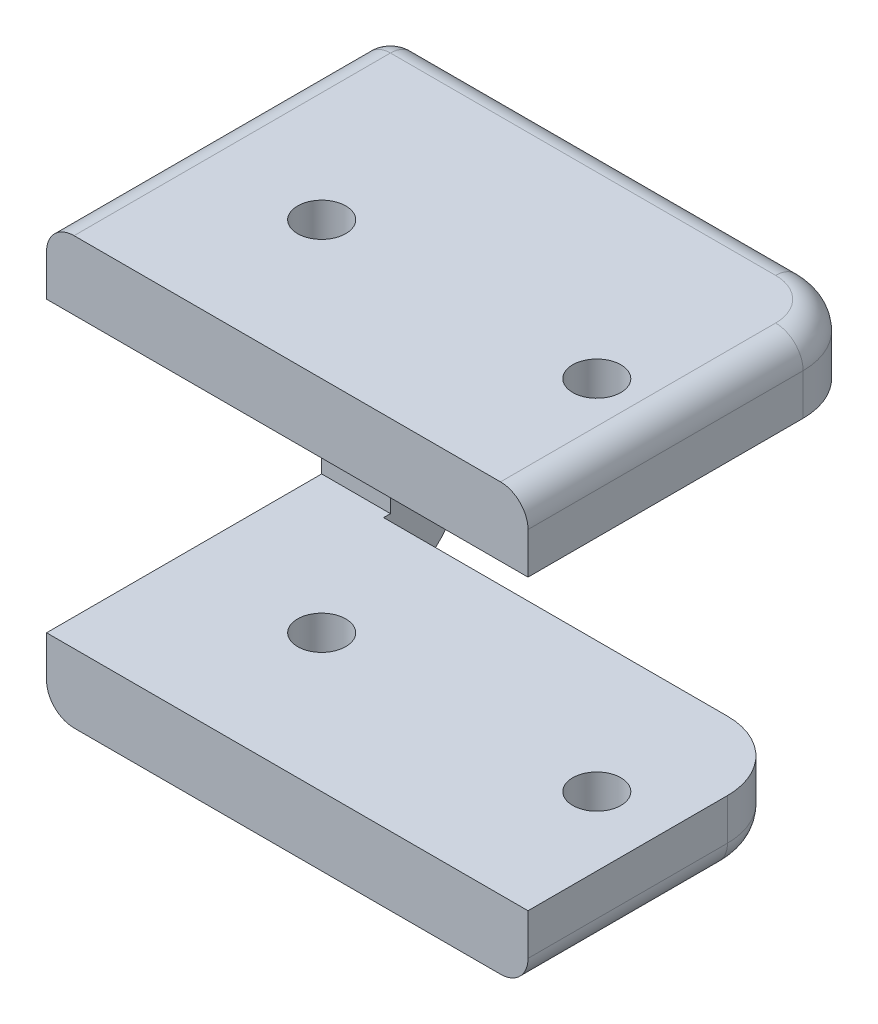
from build123d import *

# Parameters (mm, degrees)
SKETCH1_W           = 30
SKETCH1_H           = 25
SKETCH1_R           = 1.75
BOSS_EXTRUDE1_DEPTH = 5
BOSS_EXTRUDE2_DEPTH = 5
SKETCH3_W           = 19.5
SKETCH3_H           = 5
BOSS_EXTRUDE3_DEPTH = 30
SKETCH4_R           = 1.75
CUT_EXTRUDE1_DEPTH  = 32
FILLET1_R           = 5
FILLET2_R           = 2


with BuildPart() as part:
    # Sketch1 → Boss-Extrude1 (new body)
    with BuildSketch(Plane(origin=(0, 0, 0), x_dir=(1, 0, 0), z_dir=(0, 1, 0))):
        Rectangle(SKETCH1_W, SKETCH1_H)
        with Locations((-10, -2.5)):
            Circle(SKETCH1_R, mode=Mode.SUBTRACT)
        with Locations((10, -2.5)):
            Circle(SKETCH1_R, mode=Mode.SUBTRACT)
    extrude(amount=BOSS_EXTRUDE1_DEPTH)

    # Sketch2 → Boss-Extrude2 (add)
    with BuildSketch(Plane.ZY.offset(15)):
        Polygon((-12.5, 5), (12.5, 5), (12.5, 0), (-7.5, 0), (-7.5, -21), (12.5, -21), (12.5, -26), (-12.5, -26), align=None)
    extrude(amount=BOSS_EXTRUDE2_DEPTH)

    # Sketch3 → Boss-Extrude3 (add)
    with BuildSketch(Plane(origin=(-15, 0, 0), x_dir=(0, 0, -1), z_dir=(1, 0, 0))):
        with Locations((-2.75, -23.5)):
            Rectangle(SKETCH3_W, SKETCH3_H)
    extrude(amount=BOSS_EXTRUDE3_DEPTH)

    # Sketch4 → Cut-Extrude1 (cut, through all)
    with BuildSketch(Plane.XZ.offset(26)):
        with Locations((-10, 2.5)):
            Circle(SKETCH4_R)
        with Locations((10, 2.5)):
            Circle(SKETCH4_R)
    extrude(amount=-CUT_EXTRUDE1_DEPTH, mode=Mode.SUBTRACT)

    # Fillet1
    fillet1_edges = [part.edges().sort_by_distance(p)[0] for p in [
        (-17.5, -26, -12.5),
        (15, -23.5, -7),
        (15, 2.5, -12.5),
    ]]
    fillet(fillet1_edges, radius=FILLET1_R)

    # Fillet2
    fillet2_edges = [part.edges().sort_by_distance(p)[0] for p in [
        (-20, -8, -12.5),
        (-20, 5, 0),
        (15, -26, 5.25),
        (15, 5, 2.5),
        (-2.5, -26, -7),
        (-20, -26, 2.5),
        (13.535533906, -26, -5.535533906),
        (-5, 5, -12.5),
        (-20, -24.535533906, -11.035533906),
        (13.535533906, 5, -11.035533906),
    ]]
    fillet(fillet2_edges, radius=FILLET2_R)


solid = part.part
